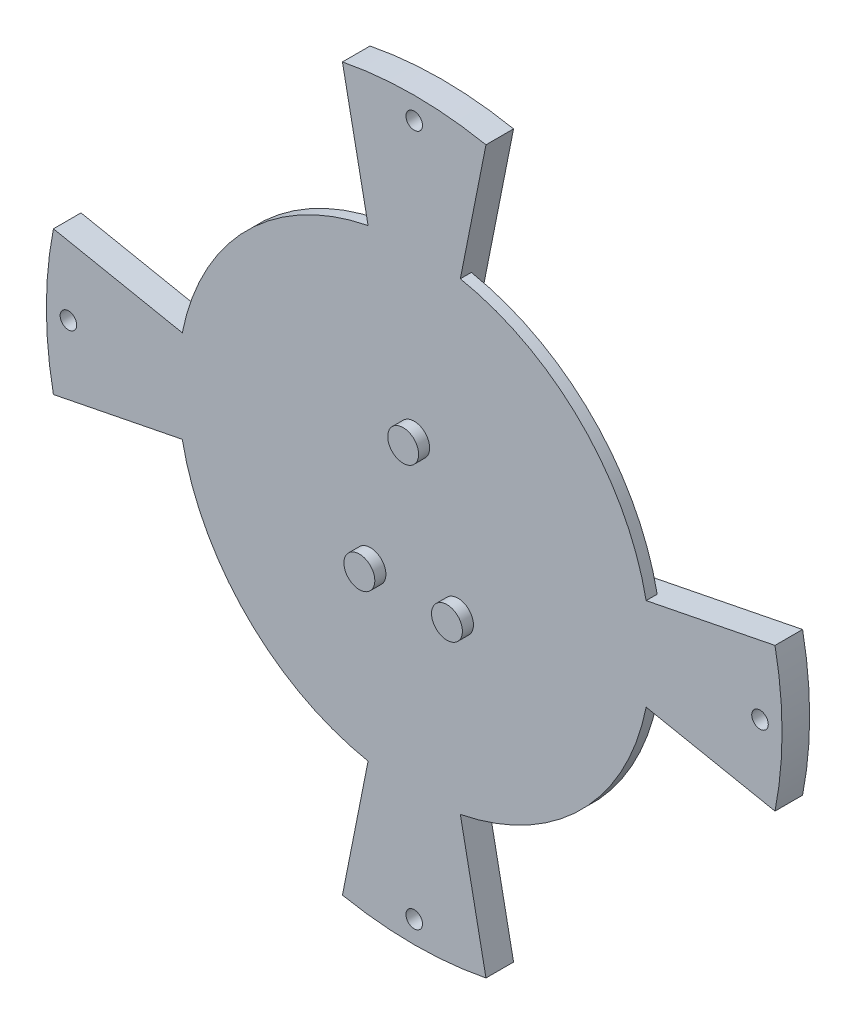
from build123d import *

# Parameters (mm, degrees)
SKETCH1_R      = 25
EXTRUDE1_DEPTH = 5
SKETCH4_R      = 1.5
EXTRUDE2_DEPTH = 5
SKETCH6_R      = 2.8
EXTRUDE4_DEPTH = 2
SKETCH7_R      = 42.8625
SKETCH7_R_2    = 23.8125
EXTRUDE5_DEPTH = 2


with BuildPart() as part:
    # Sketch1 → Extrude1 (new body)
    with BuildSketch(Plane.XY):
        Circle(SKETCH1_R)
    extrude(amount=EXTRUDE1_DEPTH)

    # Sketch4 → Extrude2 (add)
    with BuildSketch(Plane.XY.offset(5)):
        with BuildLine():
            Line((-13.007376983, 65.393912324), (-4.682070455, 23.538866078))
            ThreePointArc((-4.682070455, 23.538866078), (0, 24), (4.682070455, 23.538866078))
            Line((4.682070455, 23.538866078), (13.007376983, 65.393912324))
            ThreePointArc((13.007376983, 65.393912324), (0, 66.675), (-13.007376983, 65.393912324))
        make_face()
        with Locations((0, 62.675)):
            Circle(SKETCH4_R, mode=Mode.SUBTRACT)
        with BuildLine():
            Line((65.393912324, 13.007376983), (23.538866078, 4.682070455))
            ThreePointArc((23.538866078, 4.682070455), (24, 0), (23.538866078, -4.682070455))
            Line((23.538866078, -4.682070455), (65.393912324, -13.007376983))
            ThreePointArc((65.393912324, -13.007376983), (66.675, 0), (65.393912324, 13.007376983))
        make_face()
        with Locations((62.675, 0)):
            Circle(SKETCH4_R, mode=Mode.SUBTRACT)
        with BuildLine():
            Line((4.682070455, -23.538866078), (13.007376983, -65.393912324))
            ThreePointArc((13.007376983, -65.393912324), (0, -66.675), (-13.007376983, -65.393912324))
            Line((-13.007376983, -65.393912324), (-4.682070455, -23.538866078))
            ThreePointArc((-4.682070455, -23.538866078), (0, -24), (4.682070455, -23.538866078))
        make_face()
        with Locations((0, -62.675)):
            Circle(SKETCH4_R, mode=Mode.SUBTRACT)
        with BuildLine():
            Line((-23.538866078, -4.682070455), (-65.393912324, -13.007376983))
            ThreePointArc((-65.393912324, -13.007376983), (-66.675, 0), (-65.393912324, 13.007376983))
            Line((-65.393912324, 13.007376983), (-23.538866078, 4.682070455))
            ThreePointArc((-23.538866078, 4.682070455), (-24, 0), (-23.538866078, -4.682070455))
        make_face()
        with Locations((-62.675, 0)):
            Circle(SKETCH4_R, mode=Mode.SUBTRACT)
    extrude(amount=-EXTRUDE2_DEPTH)

    # Sketch6 → Extrude4 (add)
    with BuildSketch(Plane.XY.offset(5)):
        with Locations((-7.9375, -11.1125)):
            Circle(SKETCH6_R)
        with Locations((7.9375, -11.1125)):
            Circle(SKETCH6_R)
        with Locations((0, 12.7)):
            Circle(SKETCH6_R)
    extrude(amount=EXTRUDE4_DEPTH)

    # Sketch7 → Extrude5 (add)
    with BuildSketch(Plane.XY.offset(5)):
        Circle(SKETCH7_R)
        Circle(SKETCH7_R_2, mode=Mode.SUBTRACT)
    extrude(amount=-EXTRUDE5_DEPTH)


solid = part.part
